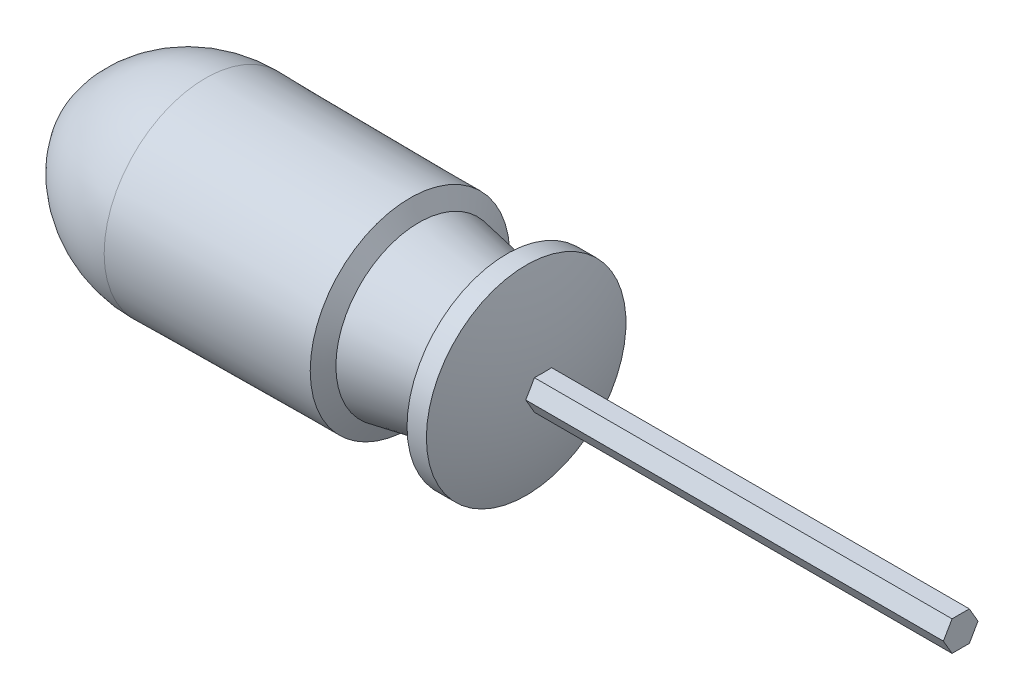
from build123d import *

# Parameters (mm, degrees)
BOSS_EXTRUDE1_DEPTH = 130


with BuildPart() as part:
    # Sketch1 → Revolve1 (revolve)
    with BuildSketch(Plane.XY):
        with BuildLine():
            Line((35.74167751, 21.648217086), (31.54167751, 21.648217086))
            ThreePointArc((31.54167751, 21.648217086), (31.095024034, 18.113017357), (29.783135154, 14.8))
            Line((29.783135154, 14.8), (12.463518384, 18))
            Line((12.463518384, 18), (10.54167751, 21.648217086))
            Line((10.54167751, 21.648217086), (-33.810765389, 21.995049121))
            ThreePointArc((-33.810765389, 21.995049121), (-49.094636558, 17.948213618), (-60.198593388, 6.693181934))
            ThreePointArc((-60.198593388, 6.693181934), (-61.144597883, 3.382154176), (-60.497402053, 0))
            Line((-60.497402053, 0), (39.502597947, 0))
            ThreePointArc((39.502597947, 0), (38.55537848, 10.98623941), (35.74167751, 21.648217086))
        make_face()
    revolve(axis=Axis((-90.082052937, 0, 0), (1, 0, 0)))

    # Sketch2 → Boss-Extrude1 (add)
    with BuildSketch(Plane(origin=(0, 0, 0), x_dir=(0, 0, -1), z_dir=(1, 0, 0))):
        Polygon((3.75277675, 0), (1.876388375, 3.25), (-1.876388375, 3.25), (-3.75277675, 0), (-1.876388375, -3.25), (1.876388375, -3.25), align=None)
    extrude(amount=BOSS_EXTRUDE1_DEPTH)


solid = part.part
